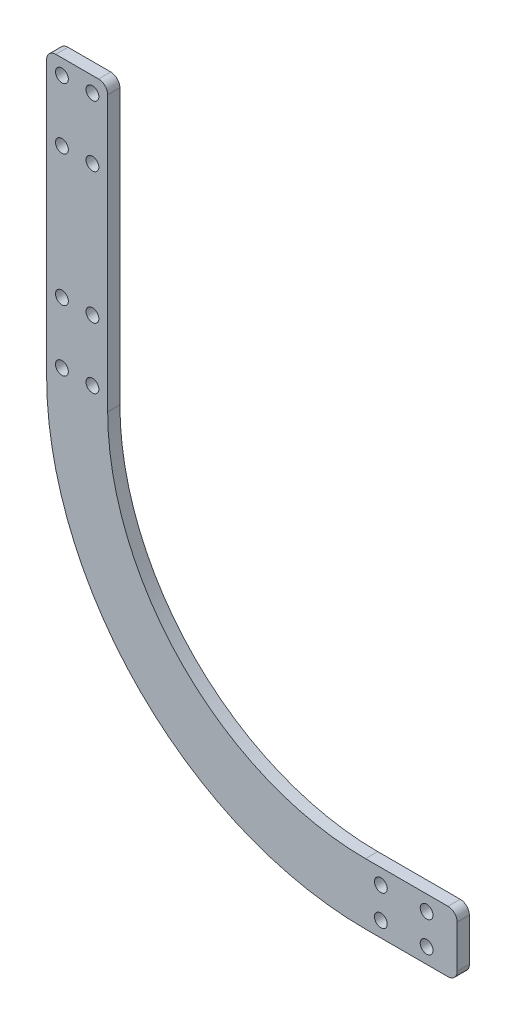
from build123d import *

# Parameters (mm, degrees)
EXTRUDE_1_DEPTH     = 4
SKETCH_5_W          = 20
SKETCH_5_H          = 93
EXTRUDE_4_DEPTH     = 4
SKETCH_6_W          = 30
SKETCH_6_H          = 20
EXTRUDE_5_DEPTH     = 4
SKETCH_7_R          = 2.1
CUT_EXTRUDE_2_DEPTH = 5
FILLET_2_R          = 3


with BuildPart() as part:
    # 草图1 → 凸台-拉伸1 (new body)
    with BuildSketch(Plane.XY):
        with BuildLine():
            Line((0, 0), (0, -20))
            ThreePointArc((0, -20), (-73.892658634, 10.607341366), (-104.5, 84.5))
            Line((-104.5, 84.5), (-84.5, 84.5))
            ThreePointArc((-84.5, 84.5), (-59.75052301, 24.74947699), (0, 0))
        make_face()
    extrude(amount=EXTRUDE_1_DEPTH)

    # 草图5 → 凸台-拉伸4 (add)
    with BuildSketch(Plane.XY.offset(4)):
        with Locations((-94.5, 131)):
            Rectangle(SKETCH_5_W, SKETCH_5_H)
    extrude(amount=-EXTRUDE_4_DEPTH)

    # 草图6 → 凸台-拉伸5 (add)
    with BuildSketch(Plane.XY.offset(4)):
        with Locations((15, -10)):
            Rectangle(SKETCH_6_W, SKETCH_6_H)
    extrude(amount=-EXTRUDE_5_DEPTH)

    # 草图7 → 切除-拉伸2 (cut, through all)
    with BuildSketch(Plane.XY.offset(4)):
        with Locations((-99.5, 109.5)):
            Circle(SKETCH_7_R)
        with Locations((-89.5, 109.5)):
            Circle(SKETCH_7_R)
        with Locations((-89.5, 89.5)):
            Circle(SKETCH_7_R)
        with Locations((-99.5, 89.5)):
            Circle(SKETCH_7_R)
        with Locations((-99.5, 152.5)):
            Circle(SKETCH_7_R)
        with Locations((-89.5, 152.5)):
            Circle(SKETCH_7_R)
        with Locations((-89.5, 172.5)):
            Circle(SKETCH_7_R)
        with Locations((-99.5, 172.5)):
            Circle(SKETCH_7_R)
        with Locations((20, -15)):
            Circle(SKETCH_7_R)
        with Locations((20, -5)):
            Circle(SKETCH_7_R)
        with Locations((5, -5)):
            Circle(SKETCH_7_R)
        with Locations((5, -15)):
            Circle(SKETCH_7_R)
    extrude(amount=-CUT_EXTRUDE_2_DEPTH, mode=Mode.SUBTRACT)

    # 圆角2
    fillet_2_edges = [part.edges().sort_by_distance(p)[0] for p in [
        (-104.5, 177.5, 2),
        (-84.5, 177.5, 2),
        (30, 0, 2),
        (30, -20, 2),
    ]]
    fillet(fillet_2_edges, radius=FILLET_2_R)


solid = part.part
